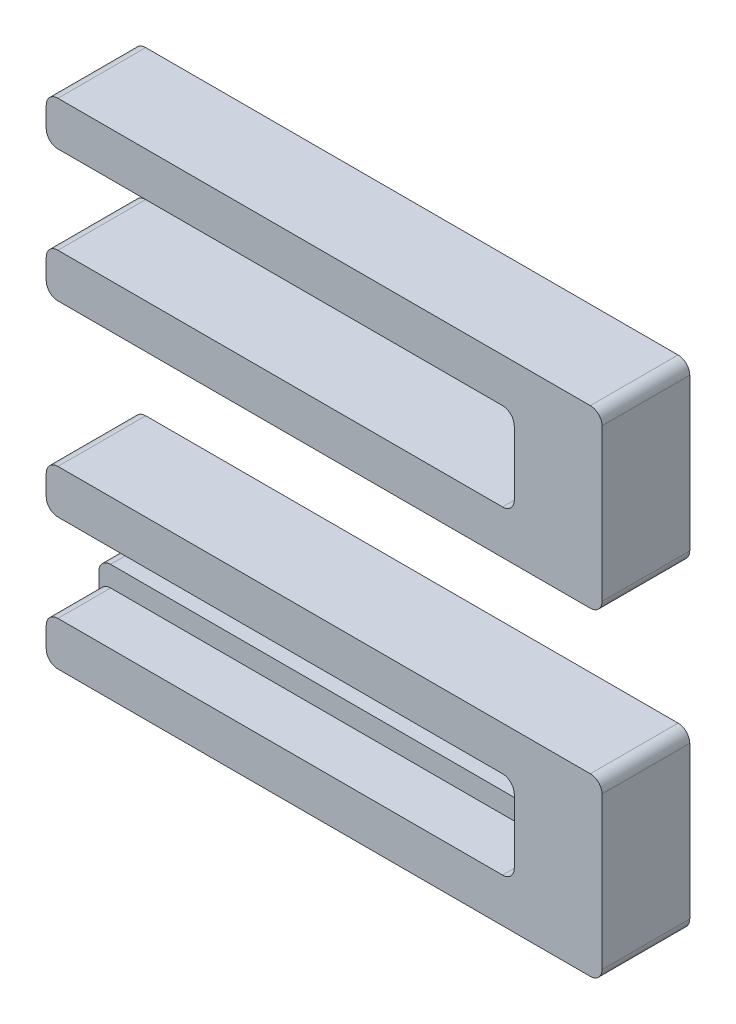
from build123d import *

# Parameters (mm, degrees)
BOSS_EXTRUDE1_DEPTH   = 3
BOSS_EXTRUDE1_2_DEPTH = 3
SKETCH2_4_W           = 16
SKETCH2_4_H           = 0.7
BOSS_EXTRUDE3_DEPTH   = 1.2
FILLET2_R             = 0.4
FILLET3_R             = 0.4


with BuildPart() as part:
    # Sketch2 → Boss-Extrude1 (new body)
    with BuildSketch(Plane.XY):
        Polygon((0, 1.5), (0, 0), (19, 0), (19, 6), (0, 6), (0, 4.5), (16, 4.5), (16, 1.5), align=None)
    extrude(amount=BOSS_EXTRUDE1_DEPTH)



with BuildPart() as body_2:
    # Sketch2 → Boss-Extrude1 2 (new body)
    with BuildSketch(Plane.XY):
        Polygon((16, -6.399471306), (16, -9.399471306), (0, -9.399471306), (0, -10.899471306), (19, -10.899471306), (19, -4.899471306), (0, -4.899471306), (0, -6.399471306), align=None)
    extrude(amount=BOSS_EXTRUDE1_2_DEPTH)


with BuildPart() as part_1:
    add(part.part)

    add(body_2.part)  # Boss-Extrude3 merges body 2
    # Sketch2_4 → Boss-Extrude3 (add)
    with BuildSketch(Plane.XY):
        with Locations((8, 4.15)):
            Rectangle(SKETCH2_4_W, SKETCH2_4_H)
        with Locations((8, -9.049471306)):
            Rectangle(SKETCH2_4_W, SKETCH2_4_H)
    extrude(amount=BOSS_EXTRUDE3_DEPTH)

    # Fillet2
    fillet2_edges = [part_1.edges().sort_by_distance(p)[0] for p in [
        (0, 4.5, 2.1),
        (16, 1.5, 1.5),
        (16, 3.8, 0.6),
        (16, 4.5, 2.1),
        (19, 6, 1.5),
        (19, 0, 1.5),
        (0, 0, 1.5),
        (0, 1.5, 1.5),
        (0, 3.8, 0.6),
        (0, 6, 1.5),
    ]]
    fillet(fillet2_edges, radius=FILLET2_R)

    # Fillet3
    fillet3_edges = [part_1.edges().sort_by_distance(p)[0] for p in [
        (19, -10.899471306, 1.5),
        (19, -4.899471306, 1.5),
        (16, -6.399471306, 1.5),
        (16, -9.399471306, 2.1),
        (16, -8.699471306, 0.6),
        (0, -10.899471306, 1.5),
        (0, -9.399471306, 2.1),
        (0, -8.699471306, 0.6),
        (0, -4.899471306, 1.5),
        (0, -6.399471306, 1.5),
    ]]
    fillet(fillet3_edges, radius=FILLET3_R)


solid = part_1.part
